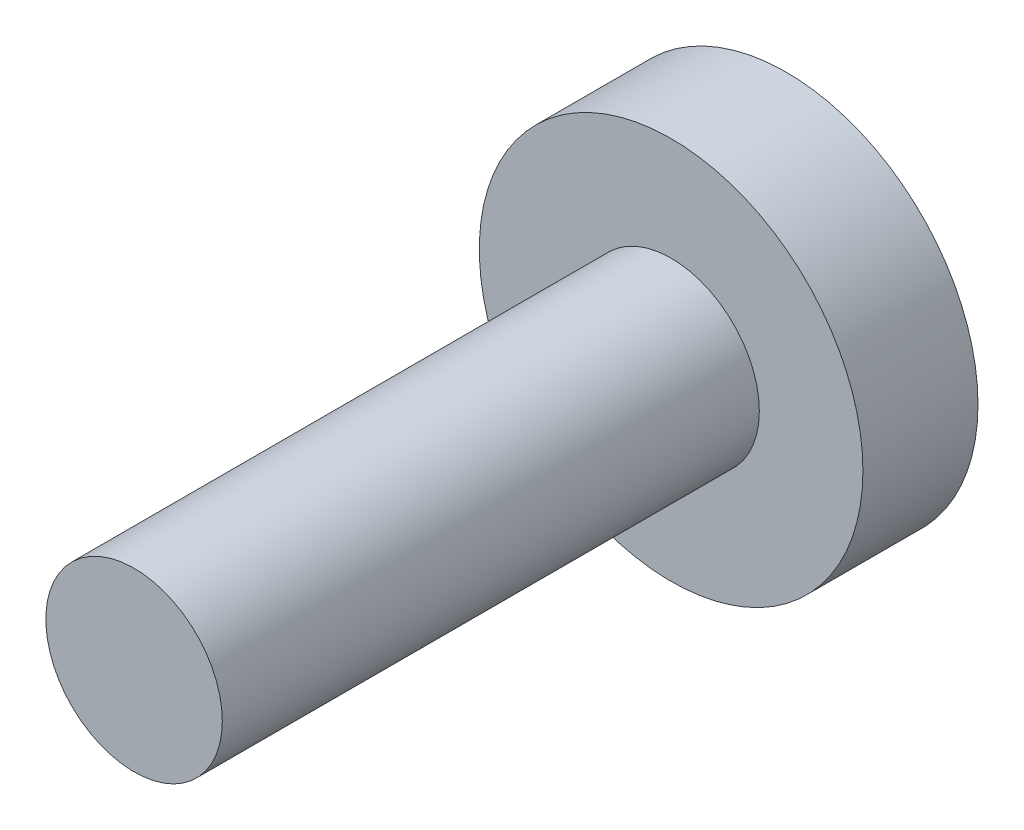
from build123d import *

# Parameters (mm, degrees)
SKETCH1_R           = 2.921
BOSS_EXTRUDE1_DEPTH = 17.78
SKETCH2_R           = 6.35
BOSS_EXTRUDE2_DEPTH = 3.81


with BuildPart() as part:
    # Sketch1 → Boss-Extrude1 (new body)
    with BuildSketch(Plane.XY):
        Circle(SKETCH1_R)
    extrude(amount=BOSS_EXTRUDE1_DEPTH)

    # Sketch2 → Boss-Extrude2 (add)
    with BuildSketch(Plane.XY):
        Circle(SKETCH2_R)
    extrude(amount=-BOSS_EXTRUDE2_DEPTH)


solid = part.part
